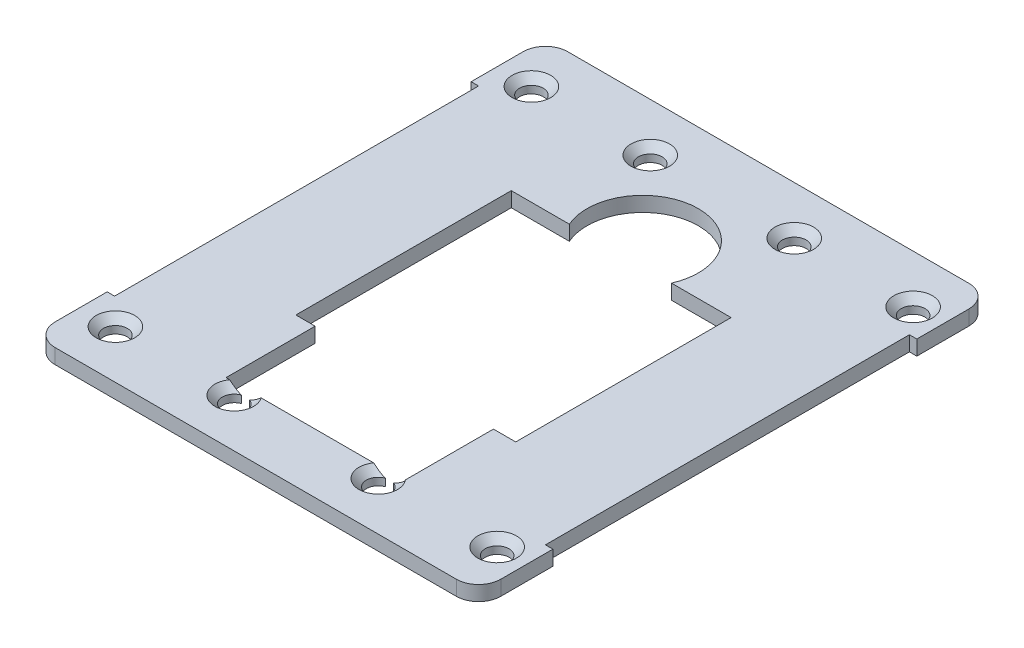
from build123d import *

# Parameters (mm, degrees)
SKETCH1_W           = 14.40065461
SKETCH1_H           = 29
SKETCH1_W_2         = 14
SKETCH1_R           = 1.35
BOSS_EXTRUDE2_DEPTH = 2
SKETCH2_R           = 7.5
CUT_EXTRUDE1_DEPTH  = 2
SKETCH3_W           = 5.497638463
SKETCH3_H           = 5.570940309
SKETCH3_W_2         = 9.162730771
SKETCH3_H_2         = 3.811696001
SKETCH3_W_3         = 6.450562463
SKETCH3_H_3         = 6.157355078
SKETCH3_W_4         = 5.570940309
SKETCH3_H_4         = 4.544714463
SKETCH3_W_5         = 6.27821864
SKETCH3_H_5         = 3.656250045
SKETCH3_W_6         = 6.338006476
SKETCH3_H_6         = 4.174139377
BOSS_EXTRUDE3_DEPTH = 2
SKETCH4_R           = 1.6
CUT_EXTRUDE2_DEPTH  = 10
CHAMFER1_SIZE       = 1
SKETCH5_W           = 10.813263603
SKETCH5_H           = 2.270321327
SKETCH5_W_2         = 10.386812418
SKETCH5_H_2         = 2.583327919
SKETCH5_W_3         = 10.884553744
SKETCH5_H_3         = 2.62287776
SKETCH5_W_4         = 12.051602383
SKETCH5_H_4         = 3.322696714
BOSS_EXTRUDE4_DEPTH = 2


with BuildPart() as part:
    # Sketch1 → Boss-Extrude2 (new body)
    with BuildSketch(Plane(origin=(0, 0, 0), x_dir=(1, 0, 0), z_dir=(0, 1, 0))):
        with Locations((-22.106428168, 0.106069008)):
            Rectangle(SKETCH1_W, SKETCH1_H)
        with Locations((21.693244527, 0.106069008)):
            Rectangle(SKETCH1_W_2, SKETCH1_H)
        with BuildLine():
            Line((22.693244527, -34.393930992), (26.693244527, -34.393930992))
            ThreePointArc((26.693244527, -34.393930992), (28.814564871, -33.515251336), (29.693244527, -31.393930992))
            Line((29.693244527, -31.393930992), (29.693244527, -24.393930992))
            Line((29.693244527, -24.393930992), (28.693244527, -24.393930992))
            Line((28.693244527, -24.393930992), (28.693244527, -14.393930992))
            Line((28.693244527, -14.393930992), (11.693244527, -14.393930992))
            Line((11.693244527, -14.393930992), (11.693244527, -26.393930992))
            Line((11.693244527, -26.393930992), (-12.306755473, -26.393930992))
            Line((-12.306755473, -26.393930992), (-12.306755473, -14.393930992))
            Line((-12.306755473, -14.393930992), (-29.306755473, -14.393930992))
            Line((-29.306755473, -14.393930992), (-29.306755473, -24.393930992))
            Line((-29.306755473, -24.393930992), (-30.306755473, -24.393930992))
            Line((-30.306755473, -24.393930992), (-30.306755473, -31.393930992))
            ThreePointArc((-30.306755473, -31.393930992), (-29.428075817, -33.515251336), (-27.306755473, -34.393930992))
            Line((-27.306755473, -34.393930992), (-25.306755473, -34.393930992))
            Line((-25.306755473, -34.393930992), (-25.306755473, -32.393930992))
            Line((-25.306755473, -32.393930992), (-15.306755473, -32.393930992))
            Line((-15.306755473, -32.393930992), (-15.306755473, -34.393930992))
            Line((-15.306755473, -34.393930992), (12.693244527, -34.393930992))
            Line((12.693244527, -34.393930992), (12.693244527, -32.393930992))
            Line((12.693244527, -32.393930992), (22.693244527, -32.393930992))
            Line((22.693244527, -32.393930992), (22.693244527, -34.393930992))
        make_face()
        with Locations((-20.98250428, -22.393930992)):
            Circle(SKETCH1_R, mode=Mode.SUBTRACT)
        with Locations((19.975772563, -22.393930992)):
            Circle(SKETCH1_R, mode=Mode.SUBTRACT)
        with Locations((-0.212217338, -28.393930992)):
            Circle(SKETCH1_R, mode=Mode.SUBTRACT)
        with BuildLine():
            Line((-23.306755473, 34.606069008), (-27.306755473, 34.606069008))
            ThreePointArc((-27.306755473, 34.606069008), (-29.428075817, 33.727389352), (-30.306755473, 31.606069008))
            Line((-30.306755473, 31.606069008), (-30.306755473, 24.606069008))
            Line((-30.306755473, 24.606069008), (-29.306755473, 24.606069008))
            Line((-29.306755473, 24.606069008), (-29.306755473, 14.606069008))
            Line((-29.306755473, 14.606069008), (28.693244527, 14.606069008))
            Line((28.693244527, 14.606069008), (28.693244527, 24.606069008))
            Line((28.693244527, 24.606069008), (29.693244527, 24.606069008))
            Line((29.693244527, 24.606069008), (29.693244527, 31.606069008))
            ThreePointArc((29.693244527, 31.606069008), (28.814564871, 33.727389352), (26.693244527, 34.606069008))
            Line((26.693244527, 34.606069008), (24.693244527, 34.606069008))
            Line((24.693244527, 34.606069008), (24.693244527, 32.606069008))
            Line((24.693244527, 32.606069008), (14.693244527, 32.606069008))
            Line((14.693244527, 32.606069008), (14.693244527, 34.606069008))
            Line((14.693244527, 34.606069008), (-13.306755473, 34.606069008))
            Line((-13.306755473, 34.606069008), (-13.306755473, 32.606069008))
            Line((-13.306755473, 32.606069008), (-23.306755473, 32.606069008))
            Line((-23.306755473, 32.606069008), (-23.306755473, 34.606069008))
        make_face()
        with Locations((-20.98250428, 22.606069008)):
            Circle(SKETCH1_R, mode=Mode.SUBTRACT)
        with Locations((-0.212217338, 28.606069008)):
            Circle(SKETCH1_R, mode=Mode.SUBTRACT)
        with Locations((19.975772563, 22.606069008)):
            Circle(SKETCH1_R, mode=Mode.SUBTRACT)
        with Locations((-0.212217338, 17.606069008)):
            Circle(SKETCH1_R, mode=Mode.SUBTRACT)
    extrude(amount=BOSS_EXTRUDE2_DEPTH)

    # Sketch2 → Cut-Extrude1 (cut)
    with BuildSketch(Plane(origin=(0, 2, 0), x_dir=(1, 0, 0), z_dir=(0, 1, 0))):
        with Locations((-0.212217338, 17.606069008)):
            Circle(SKETCH2_R)
    extrude(amount=-CUT_EXTRUDE1_DEPTH, mode=Mode.SUBTRACT)

    # Sketch3 → Boss-Extrude3 (add)
    with BuildSketch(Plane(origin=(0, 2, 0), x_dir=(1, 0, 0), z_dir=(0, 1, 0))):
        with Locations((-20.684668709, 22.829641321)):
            Rectangle(SKETCH3_W, SKETCH3_H)
        with Locations((0.426262988, 28.40058163)):
            Rectangle(SKETCH3_W_2, SKETCH3_H_2)
        with Locations((19.594695763, 21.950019167)):
            Rectangle(SKETCH3_W_3, SKETCH3_H_3)
        with Locations((20.03450684, -21.664579305)):
            Rectangle(SKETCH3_W_4, SKETCH3_H_4)
        with Locations((-1.015993077, -28.583465841)):
            Rectangle(SKETCH3_W_5, SKETCH3_H_5)
        with Locations((-20.264484702, -22.364159865)):
            Rectangle(SKETCH3_W_6, SKETCH3_H_6)
    extrude(amount=-BOSS_EXTRUDE3_DEPTH)

    # Sketch4 → Cut-Extrude2 (cut)
    with BuildSketch(Plane(origin=(0, 2, 0), x_dir=(1, 0, 0), z_dir=(0, 1, 0))):
        with BuildLine():
            ThreePointArc((-8.093244527, -27.893930992), (-8.379691654, -26.980378119), (-9.136468091, -26.393930992))
            Line((-9.136468091, -26.393930992), (-10.250020963, -26.393930992))
            ThreePointArc((-10.250020963, -26.393930992), (-10.6067974, -29.207483865), (-8.093244527, -27.893930992))
        make_face()
        with BuildLine():
            Line((-10.250020963, -26.393930992), (-9.136468091, -26.393930992))
            ThreePointArc((-9.136468091, -26.393930992), (-9.693244527, -26.293930992), (-10.250020963, -26.393930992))
        make_face()
        with Locations((-25.693244527, -27.893930992)):
            Circle(SKETCH4_R)
        with BuildLine():
            ThreePointArc((9.136468091, -26.393930992), (8.779691654, -29.207483865), (11.293244527, -27.893930992))
            ThreePointArc((11.293244527, -27.893930992), (11.0067974, -26.980378119), (10.250020963, -26.393930992))
            Line((10.250020963, -26.393930992), (9.136468091, -26.393930992))
        make_face()
        with BuildLine():
            Line((9.136468091, -26.393930992), (10.250020963, -26.393930992))
            ThreePointArc((10.250020963, -26.393930992), (9.693244527, -26.293930992), (9.136468091, -26.393930992))
        make_face()
        with Locations((25.693244527, -27.893930992)):
            Circle(SKETCH4_R)
        with Locations((25.693244527, 28.106069008)):
            Circle(SKETCH4_R)
        with Locations((9.693244527, 28.106069008)):
            Circle(SKETCH4_R)
        with Locations((-9.693244527, 28.106069008)):
            Circle(SKETCH4_R)
        with Locations((-25.693244527, 28.106069008)):
            Circle(SKETCH4_R)
    extrude(amount=-CUT_EXTRUDE2_DEPTH, mode=Mode.SUBTRACT)

    # Chamfer1
    chamfer1_edges = [part.edges().sort_by_distance(p)[0] for p in [
        (-27.293244527, 2, 27.893930992),
        (8.779691654, 2, 29.207483865),
        (24.093244527, 2, 27.893930992),
        (24.093244527, 2, -28.106069008),
        (8.093244527, 2, -28.106069008),
        (-11.293244527, 2, -28.106069008),
        (-27.293244527, 2, -28.106069008),
        (-10.6067974, 2, 29.207483865),
    ]]
    chamfer(chamfer1_edges, length=CHAMFER1_SIZE)

    # Sketch5 → Boss-Extrude4 (add)
    with BuildSketch(Plane(origin=(0, 2, 0), x_dir=(1, 0, 0), z_dir=(0, 1, 0))):
        with Locations((20.099876329, 33.470908345)):
            Rectangle(SKETCH5_W, SKETCH5_H)
        with Locations((-18.113349264, 33.314405048)):
            Rectangle(SKETCH5_W_2, SKETCH5_H_2)
        with Locations((-20.749032345, -33.082492112)):
            Rectangle(SKETCH5_W_3, SKETCH5_H_3)
        with Locations((16.667443335, -32.732582635)):
            Rectangle(SKETCH5_W_4, SKETCH5_H_4)
    extrude(amount=-BOSS_EXTRUDE4_DEPTH)


solid = part.part
